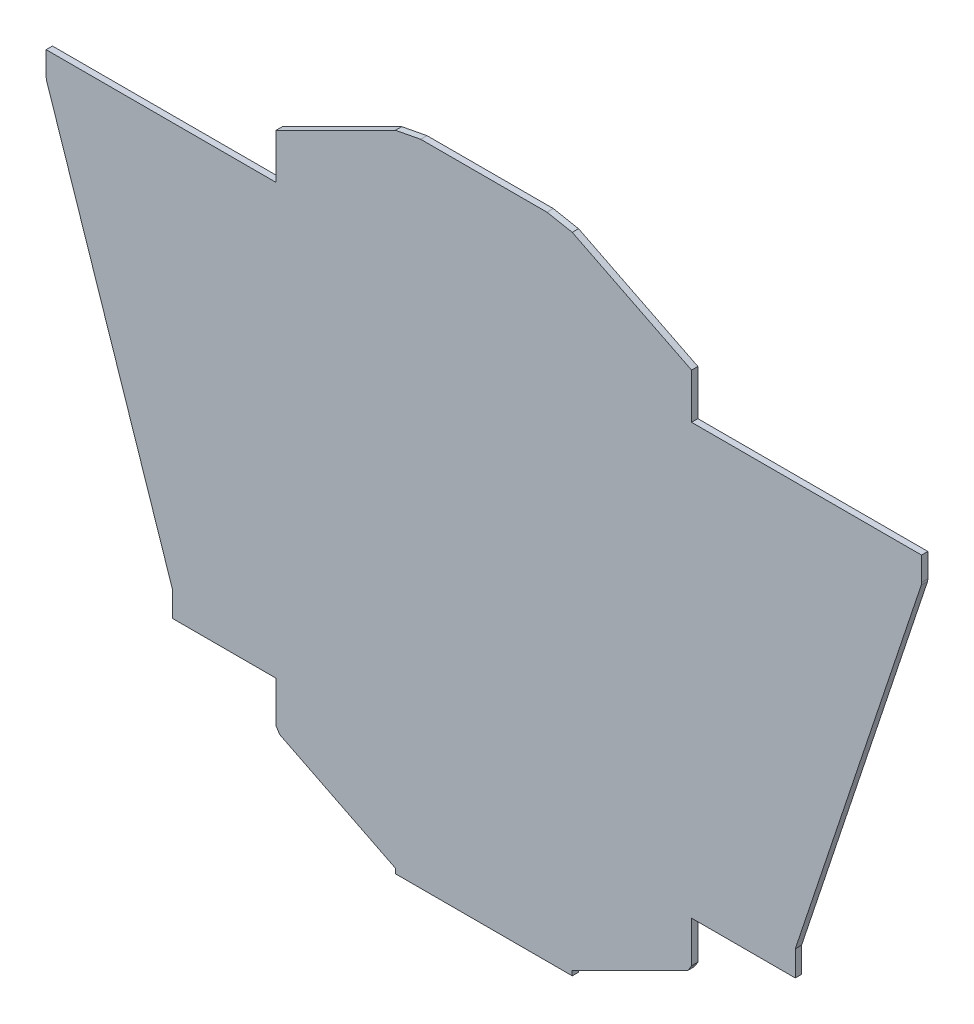
from build123d import *

# Parameters (mm, degrees)
BOSS_EXTRUDE1_DEPTH = 12.7


with BuildPart() as part:
    # Sketch1 → Boss-Extrude1 (new body)
    with BuildSketch(Plane.XY):
        Polygon((-207.569853327, -422.408510368), (-37.10675463, -422.408510368), (-37.10675463, -505.433281316), (-30.086367293, -516.792506642), (202.852470696, -633.261925636), (202.852470696, -642.963862322), (380.652470696, -642.963862322), (380.652470696, 661.746841587), (253.652470696, 661.746841587), (202.852470696, 652.044904901), (-37.10675463, 532.065292238), (-37.10675463, 441.191489632), (-461.569853327, 441.191489632), (-499.669853327, 441.191489632), (-499.669853327, 393.865899836), (-499.018131212, 388.436323288), (-245.669853327, -371.608510368), (-245.669853327, -422.408510368), align=None)
    extrude(amount=BOSS_EXTRUDE1_DEPTH)

    # Mirror1: part across plane


with BuildPart() as part_1:
    add(part.part)
    add(part.part.mirror(Plane(origin=(380.652470696, 661.746841587, 12.7), x_dir=(0, 0, 1), z_dir=(-1, 0, 0))))


solid = part_1.part
